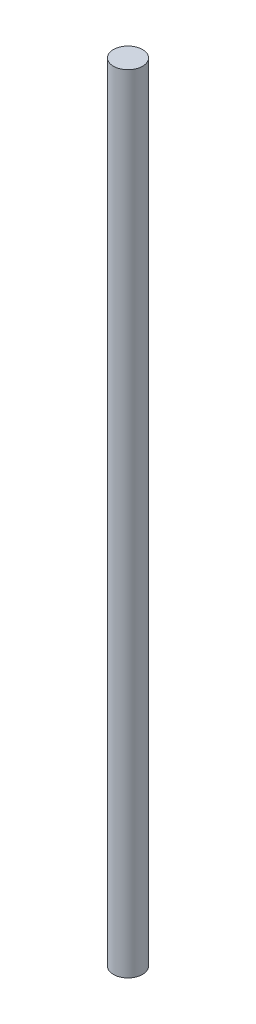
from build123d import *

# Parameters (mm, degrees)
SKETCH2_R           = 4.7625
BOSS_EXTRUDE1_DEPTH = 257.81


with BuildPart() as part:
    # Sketch2 → Boss-Extrude1 (new body)
    with BuildSketch(Plane(origin=(0, 0, 0), x_dir=(1, 0, 0), z_dir=(0, 1, 0))):
        Circle(SKETCH2_R)
    extrude(amount=BOSS_EXTRUDE1_DEPTH)


solid = part.part
